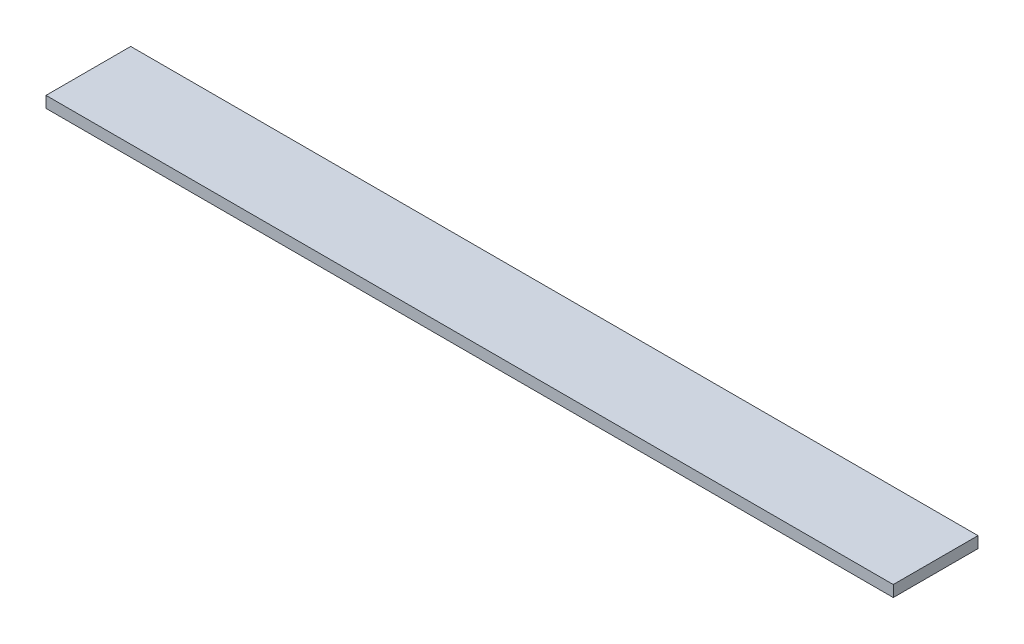
from build123d import *

# Parameters (mm, degrees)
SKETCH_1_W      = 30
SKETCH_1_H      = 4
EXTRUDE_1_DEPTH = 300


with BuildPart() as part:
    # Эскиз1 → Бобышка-Вытянуть1 (new body)
    with BuildSketch(Plane(origin=(0, 0, 0), x_dir=(0, 0, -1), z_dir=(1, 0, 0))):
        Rectangle(SKETCH_1_W, SKETCH_1_H)
    extrude(amount=EXTRUDE_1_DEPTH)


solid = part.part
